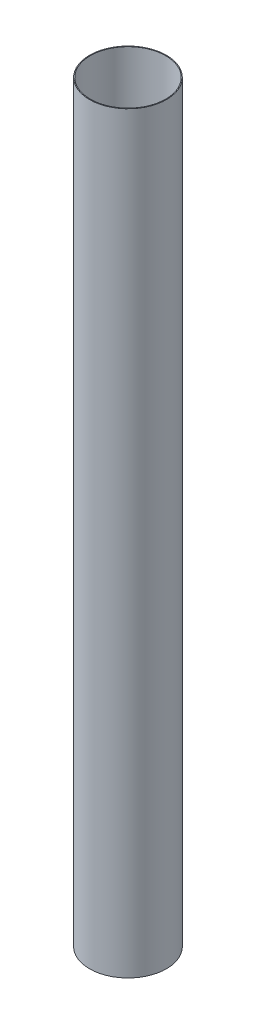
from build123d import *

# Parameters (mm, degrees)
SKETCH1_R           = 77.8637
SKETCH1_R_2         = 76.2889
BOSS_EXTRUDE1_DEPTH = 1524


with BuildPart() as part:
    # Sketch1 → Boss-Extrude1 (new body)
    with BuildSketch(Plane(origin=(0, 0, 0), x_dir=(1, 0, 0), z_dir=(0, 1, 0))):
        Circle(SKETCH1_R)
        Circle(SKETCH1_R_2, mode=Mode.SUBTRACT)
    extrude(amount=BOSS_EXTRUDE1_DEPTH)


solid = part.part
